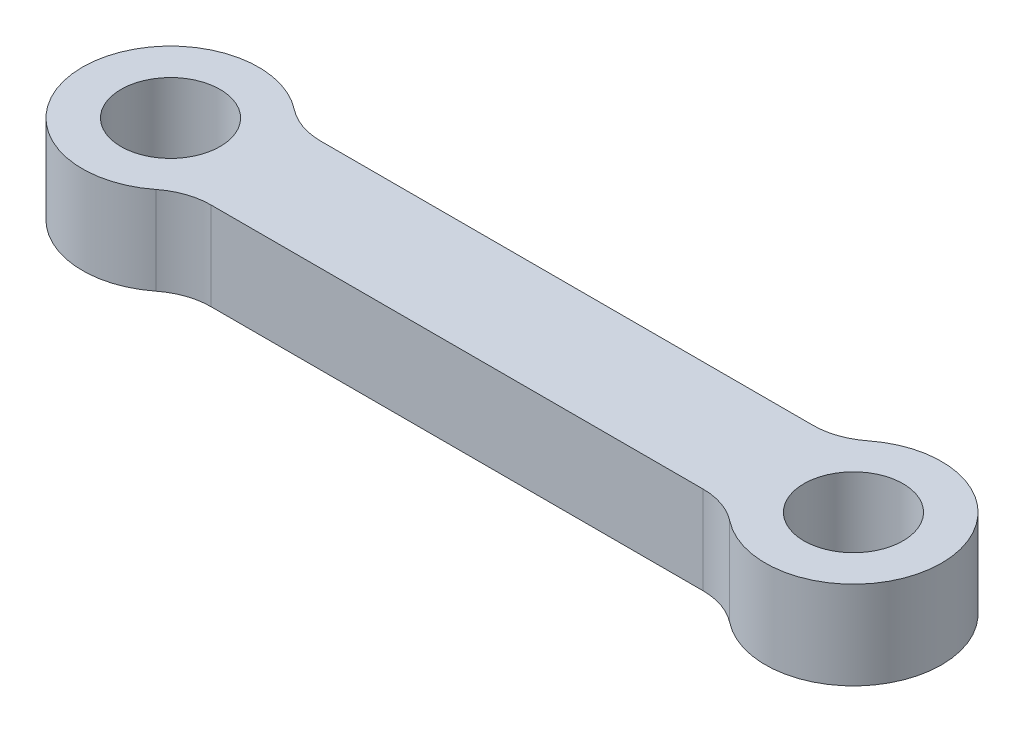
from build123d import *

# Parameters (mm, degrees)
SKETCH1_R           = 2.25
BOSS_EXTRUDE1_DEPTH = 4
FILLET1_R           = 3


with BuildPart() as part:
    # Sketch1 → Boss-Extrude1 (new body)
    with BuildSketch(Plane(origin=(0, 0, 0), x_dir=(1, 0, 0), z_dir=(0, 1, 0))):
        with BuildLine():
            Line((27.877501001, 2.5), (3.122498999, 2.5))
            ThreePointArc((3.122498999, 2.5), (-4, 0), (3.122498999, -2.5))
            Line((3.122498999, -2.5), (27.877501001, -2.5))
            ThreePointArc((27.877501001, -2.5), (35, 0), (27.877501001, 2.5))
        make_face()
        Circle(SKETCH1_R, mode=Mode.SUBTRACT)
        with Locations((31, 0)):
            Circle(SKETCH1_R, mode=Mode.SUBTRACT)
    extrude(amount=BOSS_EXTRUDE1_DEPTH)

    # Fillet1
    fillet1_edges = [part.edges().sort_by_distance(p)[0] for p in [
        (27.877501001, 2, 2.5),
        (3.122498999, 2, 2.5),
        (3.122498999, 2, -2.5),
        (27.877501001, 2, -2.5),
    ]]
    fillet(fillet1_edges, radius=FILLET1_R)


solid = part.part
